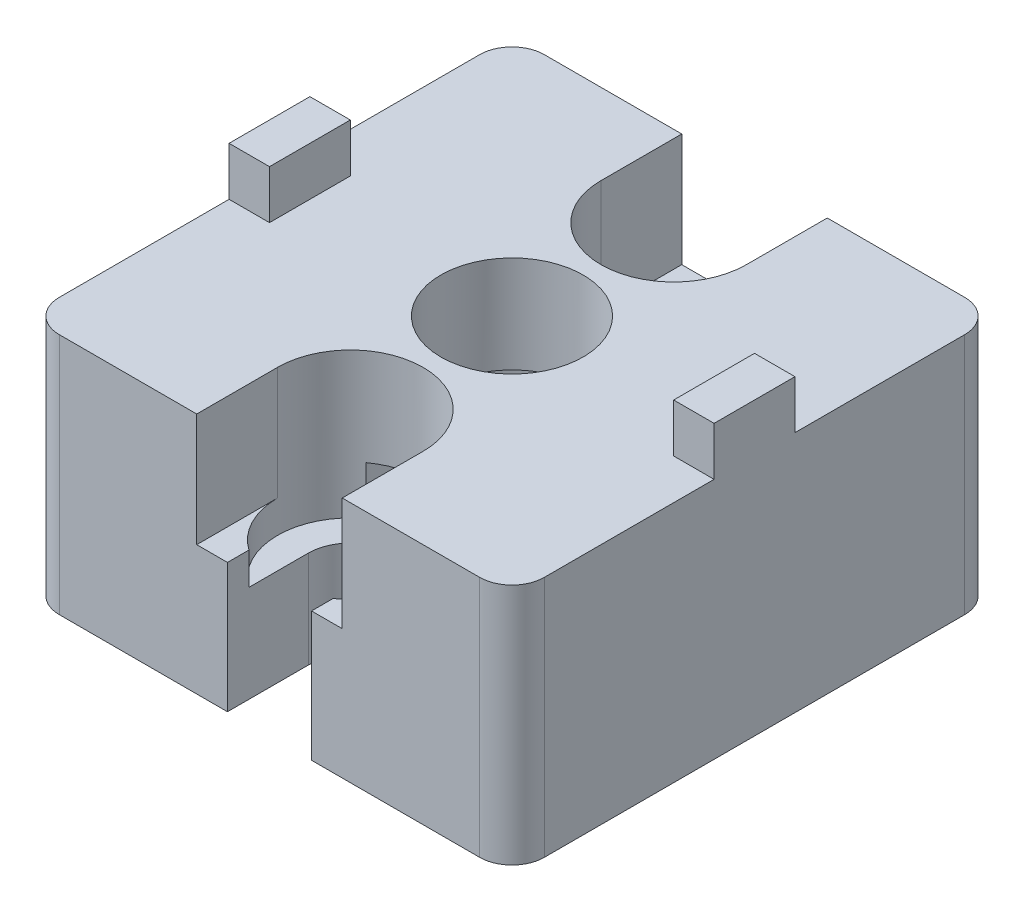
from build123d import *

# Parameters (mm, degrees)
EXTRUDE_1_DEPTH     = 15
EXTRUDE_2_DEPTH     = 3
SKETCH_3_R          = 4.4
CUT_EXTRUDE_1_DEPTH = 26.980762113533164
SKETCH_4_R          = 6.9
CUT_EXTRUDE_2_DEPTH = 9
CUT_EXTRUDE_3_DEPTH = 7
SKETCH_6_R          = 4.5
SKETCH_6_R_2        = 4.499999999999997
CUT_EXTRUDE_4_DEPTH = 2
FILLET_1_R          = 2


with BuildPart() as part:
    # Эскиз1 → Бобышка-Вытянуть1 (new body)
    with BuildSketch(Plane(origin=(0, 0, 0), x_dir=(1, 0, 0), z_dir=(0, 1, 0))):
        Polygon((14.999999999999998, 15.000000000000004), (-15.000000000000002, 15), (-14.999999999999998, -15), (15.000000000000002, -14.999999999999996), align=None)
    extrude(amount=EXTRUDE_1_DEPTH)

    # Эскиз2 → Бобышка-Вытянуть2 (add)
    with BuildSketch(Plane(origin=(0, 15, 0), x_dir=(1, 0, 0), z_dir=(0, 1, 0))):
        Polygon((-12.5, -2.499999999999997), (-15.000000000000002, -2.4999999999999973), (-15.000000000000002, 2.5000000000000027), (-12.5, 2.500000000000003), align=None)
        Polygon((15.000000000000002, -2.4999999999999973), (15.000000000000002, 2.5000000000000027), (12.5, 2.500000000000003), (12.5, -2.499999999999997), align=None)
    extrude(amount=EXTRUDE_2_DEPTH)

    # Эскиз3 → Вырез-Вытянуть1 (cut, through all)
    with BuildSketch(Plane(origin=(0, 15, 0), x_dir=(1, 0, 0), z_dir=(0, 1, 0))):
        with Locations(Location((0, 0, 0), (0, 0, 270))):
            Circle(SKETCH_3_R)
        with BuildLine():
            Line((-2.6, -15), (-2.6, -10))
            ThreePointArc((-2.6, -10), (1.6e-16, -7.4), (2.6, -10))
            Line((2.6, -10), (2.6, -15))
            Line((2.6, -15), (-2.6, -15))
        make_face()
        with BuildLine():
            Line((2.5999999999999974, 10), (2.6, 15))
            Line((2.6, 15), (-2.6, 15))
            Line((-2.6, 15), (-2.6000000000000023, 10))
            ThreePointArc((-2.6000000000000023, 10), (-2.93e-15, 7.4), (2.5999999999999974, 10))
        make_face()
    extrude(amount=-CUT_EXTRUDE_1_DEPTH, mode=Mode.SUBTRACT)

    # Эскиз4 → Вырез-Вытянуть2 (cut)
    with BuildSketch(Plane.XZ):
        with Locations(Location((0, 0, 0), (0, 0, 270))):
            Circle(SKETCH_4_R)
    extrude(amount=-CUT_EXTRUDE_2_DEPTH, mode=Mode.SUBTRACT)

    # Эскиз5 → Вырез-Вытянуть3 (cut)
    with BuildSketch(Plane(origin=(0, 15, 0), x_dir=(1, 0, 0), z_dir=(0, 1, 0))):
        with BuildLine():
            Line((-4.499999999999999, -15), (-4.5, -10))
            ThreePointArc((-4.5, -10), (2.8e-16, -5.5), (4.5, -10))
            Line((4.5, -10), (4.500000000000001, -15))
            Line((4.500000000000001, -15), (-4.499999999999999, -15))
        make_face()
        with BuildLine():
            Line((4.5, 10), (4.500000000000001, 15))
            Line((4.500000000000001, 15), (-4.499999999999999, 15))
            Line((-4.499999999999999, 15), (-4.5, 10))
            ThreePointArc((-4.5, 10), (-8.3e-16, 5.5), (4.5, 10))
        make_face()
    extrude(amount=-CUT_EXTRUDE_3_DEPTH, mode=Mode.SUBTRACT)

    # Эскиз6 → Вырез-Вытянуть4 (cut)
    with BuildSketch(Plane(origin=(0, 8, 0), x_dir=(1, 0, 0), z_dir=(0, 1, 0))):
        with Locations((0, -10)):
            Circle(SKETCH_6_R)
        with Locations((-2.45e-15, 10)):
            Circle(SKETCH_6_R_2)
    extrude(amount=-CUT_EXTRUDE_4_DEPTH, mode=Mode.SUBTRACT)

    # Скругление1
    fillet_1_edges = [part.edges().sort_by_distance(p)[0] for p in [
        (-15.000000000000002, 7.5, -15),
        (14.999999999999998, 7.5, -15.000000000000004),
        (15.000000000000002, 7.5, 14.999999999999996),
        (-14.999999999999998, 7.5, 15),
    ]]
    fillet(fillet_1_edges, radius=FILLET_1_R)


solid = part.part
